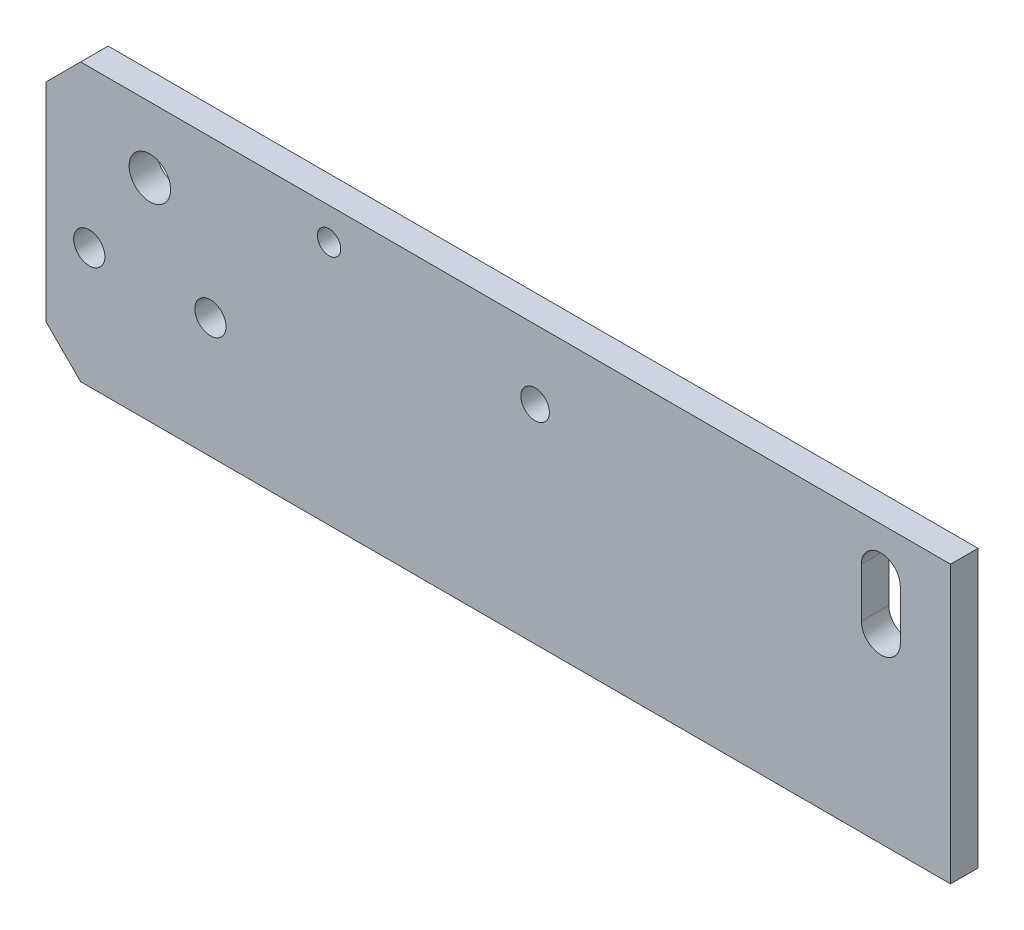
from build123d import *

# Parameters (mm, degrees)
SKETCH1_W             = 104.516
SKETCH1_H             = 32
SKETCH1_R             = 2.4
SKETCH1_R_2           = 1.8034
BOSS_EXTRUDE1_DEPTH   = 3.175
M4X0_7_TAPPED_HOLE1_D = 3.3
CHAMFER1_SIZE         = 4
F_6_32_TAPPED_HOLE1_D = 2.7051


with BuildPart() as part:
    # Sketch1 → Boss-Extrude1 (new body)
    with BuildSketch(Plane.XY):
        with Locations((-24.258, 17)):
            Rectangle(SKETCH1_W, SKETCH1_H)
        with Locations((-64.516, 25.4)):
            Circle(SKETCH1_R, mode=Mode.SUBTRACT)
        with Locations((-57.516, 14.9)):
            Circle(SKETCH1_R_2, mode=Mode.SUBTRACT)
        with Locations((-71.516, 14.9)):
            Circle(SKETCH1_R_2, mode=Mode.SUBTRACT)
        with BuildLine():
            Line((22.198129856, 27.852934279), (22.198129856, 22.147065721))
            ThreePointArc((22.198129856, 22.147065721), (19.948129856, 19.897065721), (17.698129856, 22.147065721))
            Line((17.698129856, 22.147065721), (17.698129856, 27.852934279))
            ThreePointArc((17.698129856, 27.852934279), (19.948129856, 30.102934279), (22.198129856, 27.852934279))
        make_face(mode=Mode.SUBTRACT)
    extrude(amount=-BOSS_EXTRUDE1_DEPTH)

    # M4x0.7 Tapped Hole1 (through all)
    with Locations(Plane(origin=(0, 0, -3.175), x_dir=(-1, 0, 0), z_dir=(0, 0, -1))):
        with Locations((20, 25)):
            Hole(M4X0_7_TAPPED_HOLE1_D / 2)

    # Chamfer1
    chamfer1_edges = [part.edges().sort_by_distance(p)[0] for p in [
        (-76.516, 1, -1.5875),
        (-76.516, 33, -1.5875),
    ]]
    chamfer(chamfer1_edges, length=CHAMFER1_SIZE)

    # 6-32 Tapped Hole1 (through all)
    with Locations(Plane.XY):
        with Locations((-43.81, 29.3078)):
            Hole(F_6_32_TAPPED_HOLE1_D / 2)


solid = part.part
